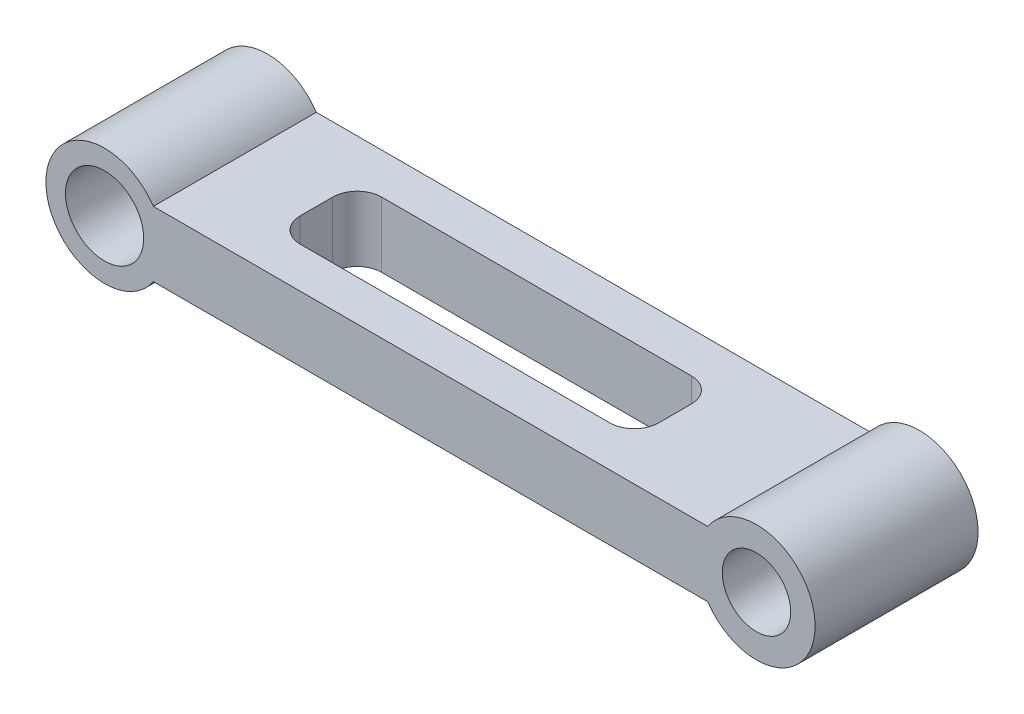
from build123d import *

# Parameters (mm, degrees)
SKETCH2_R           = 24
SKETCH2_R_2         = 21
BOSS_EXTRUDE1_DEPTH = 50
CUT_EXTRUDE1_DEPTH  = 57


with BuildPart() as part:
    # Sketch2 → Boss-Extrude1 (new body, symmetric)
    with BuildSketch(Plane.XY):
        with BuildLine():
            Line((29.933259094, 20), (370.066740906, 20))
            ThreePointArc((370.066740906, 20), (436, 0), (370.066740906, -20))
            Line((370.066740906, -20), (29.933259094, -20))
            ThreePointArc((29.933259094, -20), (-36, 0), (29.933259094, 20))
        make_face()
        Circle(SKETCH2_R, mode=Mode.SUBTRACT)
        with Locations((400, 0)):
            Circle(SKETCH2_R_2, mode=Mode.SUBTRACT)
    extrude(amount=BOSS_EXTRUDE1_DEPTH, both=True)

    # Sketch3 → Cut-Extrude1 (cut, through all)
    with BuildSketch(Plane(origin=(0, 20, 0), x_dir=(1, 0, 0), z_dir=(0, 1, 0))):
        with BuildLine():
            Line((95, 25), (285, 25))
            ThreePointArc((285, 25), (295.606601718, 20.606601718), (300, 10))
            Line((300, 10), (300, -10))
            ThreePointArc((300, -10), (295.606601718, -20.606601718), (285, -25))
            Line((285, -25), (95, -25))
            ThreePointArc((95, -25), (84.393398282, -20.606601718), (80, -10))
            Line((80, -10), (80, 10))
            ThreePointArc((80, 10), (84.393398282, 20.606601718), (95, 25))
        make_face()
    extrude(amount=-CUT_EXTRUDE1_DEPTH, mode=Mode.SUBTRACT)


solid = part.part
